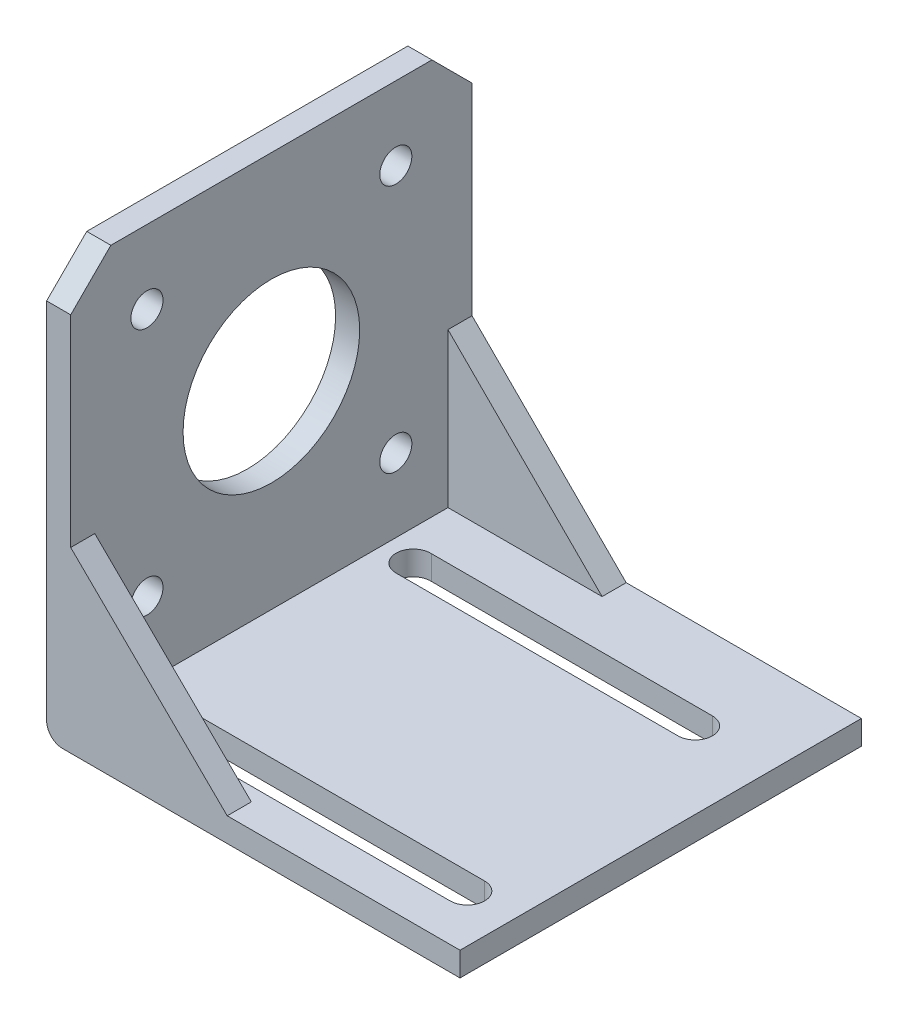
from build123d import *

# Parameters (mm, degrees)
BOSS_EXTRUDE1_DEPTH = 50
RIB1_REACH          = 87.339
SKETCH8_WALL_W      = 200.043796972
SKETCH8_WALL_H      = 3
RIB2_REACH          = 87.339
SKETCH10_WALL_W     = 199.830842734
SKETCH10_WALL_H     = 3
FILLET1_R           = 2
SKETCH11_R          = 11
SKETCH11_R_2        = 2
CUT_EXTRUDE1_DEPTH  = 50
CHAMFER1_SIZE       = 5
CUT_EXTRUDE2_DEPTH  = 50


with BuildPart() as part:
    # Sketch1 → Boss-Extrude1 (new body)
    with BuildSketch(Plane.XY):
        Polygon((0, 0), (0, 49.3), (-3, 49.3), (-3, -3), (48.5, -3), (48.5, 0), align=None)
    extrude(amount=BOSS_EXTRUDE1_DEPTH)

    # Sketch8 wall → Rib1 (add, up to next)
    with BuildSketch(Plane(origin=(9.75, 9.6, 50), x_dir=(0.712566819448, -0.701604252995, 0), z_dir=(0.701604252995, 0.712566819448, 0)), mode=Mode.PRIVATE) as rib1_sk1:
        with Locations((0, 1.5)):
            Rectangle(SKETCH8_WALL_W, SKETCH8_WALL_H)
    rib1_tool1 = extrude(rib1_sk1.sketch, amount=-RIB1_REACH, mode=Mode.PRIVATE) - part.part
    add(rib1_tool1.solids().sort_by_distance((9.75, 9.6, 50))[0])

    # Sketch10 wall → Rib2 (add, up to next)
    with BuildSketch(Plane(origin=(9.6, 9.6, 0), x_dir=(0.707106781187, -0.707106781187, 0), z_dir=(0.707106781187, 0.707106781187, 0)), mode=Mode.PRIVATE) as rib2_sk1:
        with Locations((0, -1.5)):
            Rectangle(SKETCH10_WALL_W, SKETCH10_WALL_H)
    rib2_tool1 = extrude(rib2_sk1.sketch, amount=-RIB2_REACH, mode=Mode.PRIVATE) - part.part
    add(rib2_tool1.solids().sort_by_distance((9.6, 9.6, 0))[0])

    # Fillet1
    fillet1_edges = [part.edges().sort_by_distance(p)[0] for p in [
        (-3, -3, 25),
    ]]
    fillet(fillet1_edges, radius=FILLET1_R)

    # Sketch11 → Cut-Extrude1 (cut)
    with BuildSketch(Plane(origin=(0, 0, 0), x_dir=(0, 0, -1), z_dir=(1, 0, 0))):
        with Locations(Location((-25, 24.65, 0), (0, 0, 90))):
            Circle(SKETCH11_R)
        with Locations(Location((-40.5, 40.15, 0), (0, 0, 90))):
            Circle(SKETCH11_R_2)
        with Locations(Location((-9.5, 40.15, 0), (0, 0, 90))):
            Circle(SKETCH11_R_2)
        with Locations(Location((-9.5, 9.15, 0), (0, 0, 90))):
            Circle(SKETCH11_R_2)
        with Locations(Location((-40.5, 9.15, 0), (0, 0, 90))):
            Circle(SKETCH11_R_2)
    extrude(amount=-CUT_EXTRUDE1_DEPTH, mode=Mode.SUBTRACT)

    # Chamfer1
    chamfer1_edges = [part.edges().sort_by_distance(p)[0] for p in [
        (-1.5, 49.3, 50),
        (-1.5, 49.3, 0),
    ]]
    chamfer(chamfer1_edges, length=CHAMFER1_SIZE)

    # Sketch12 → Cut-Extrude2 (cut)
    with BuildSketch(Plane.XZ.offset(3)):
        with BuildLine():
            Line((38.94922721, 9), (3.928025493, 9))
            ThreePointArc((3.928025493, 9), (1.678310919, 11.099272288), (3.828882318, 13.3))
            Line((3.828882318, 13.3), (38.94922721, 13.3))
            ThreePointArc((38.94922721, 13.3), (41.09922721, 11.15), (38.94922721, 9))
        make_face()
        with BuildLine():
            Line((3.039672714, 41), (42.571371384, 41))
            ThreePointArc((42.571371384, 41), (44.721371384, 43.15), (42.571371384, 45.3))
            Line((42.571371384, 45.3), (3.039672714, 45.3))
            ThreePointArc((3.039672714, 45.3), (0.889672714, 43.15), (3.039672714, 41))
        make_face()
    extrude(amount=-CUT_EXTRUDE2_DEPTH, mode=Mode.SUBTRACT)


solid = part.part
